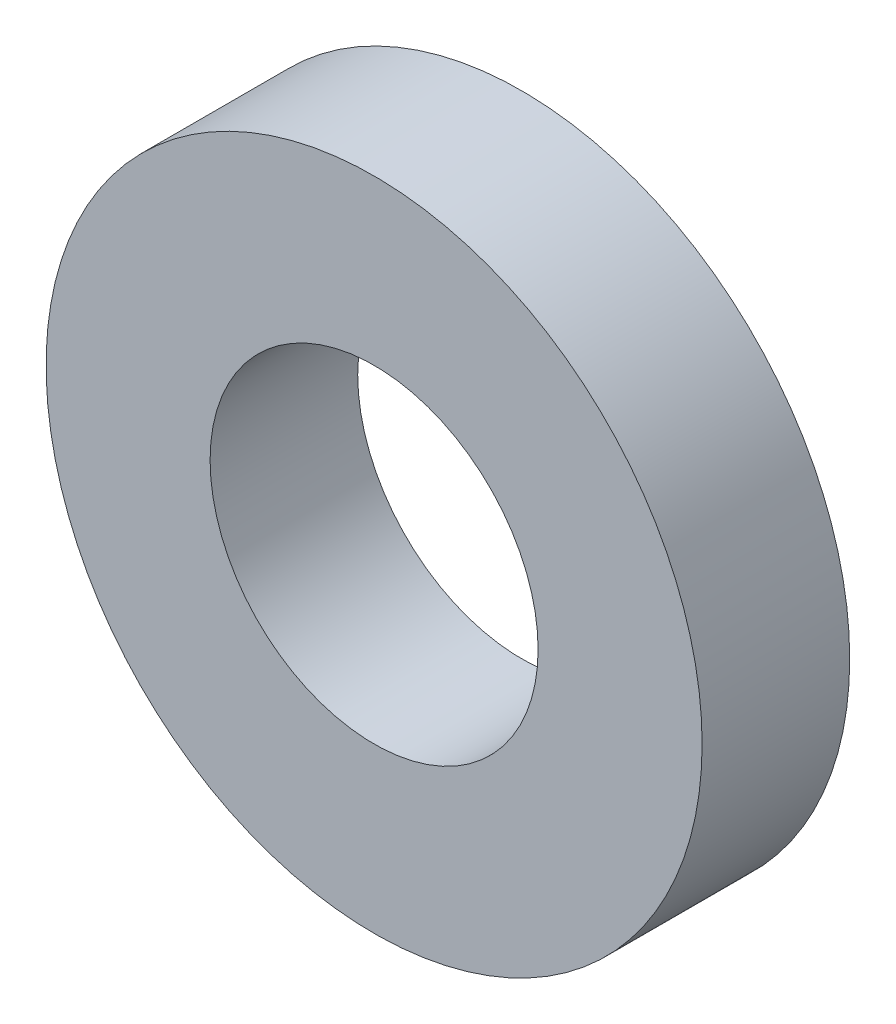
from build123d import *

# Parameters (mm, degrees)
SKETCH_1_R      = 40
SKETCH_1_R_2    = 20
EXTRUDE_1_DEPTH = 18


with BuildPart() as part:
    # 草图1 → 凸台-拉伸1 (new body)
    with BuildSketch(Plane.XY):
        Circle(SKETCH_1_R)
        Circle(SKETCH_1_R_2, mode=Mode.SUBTRACT)
    extrude(amount=EXTRUDE_1_DEPTH)


solid = part.part
